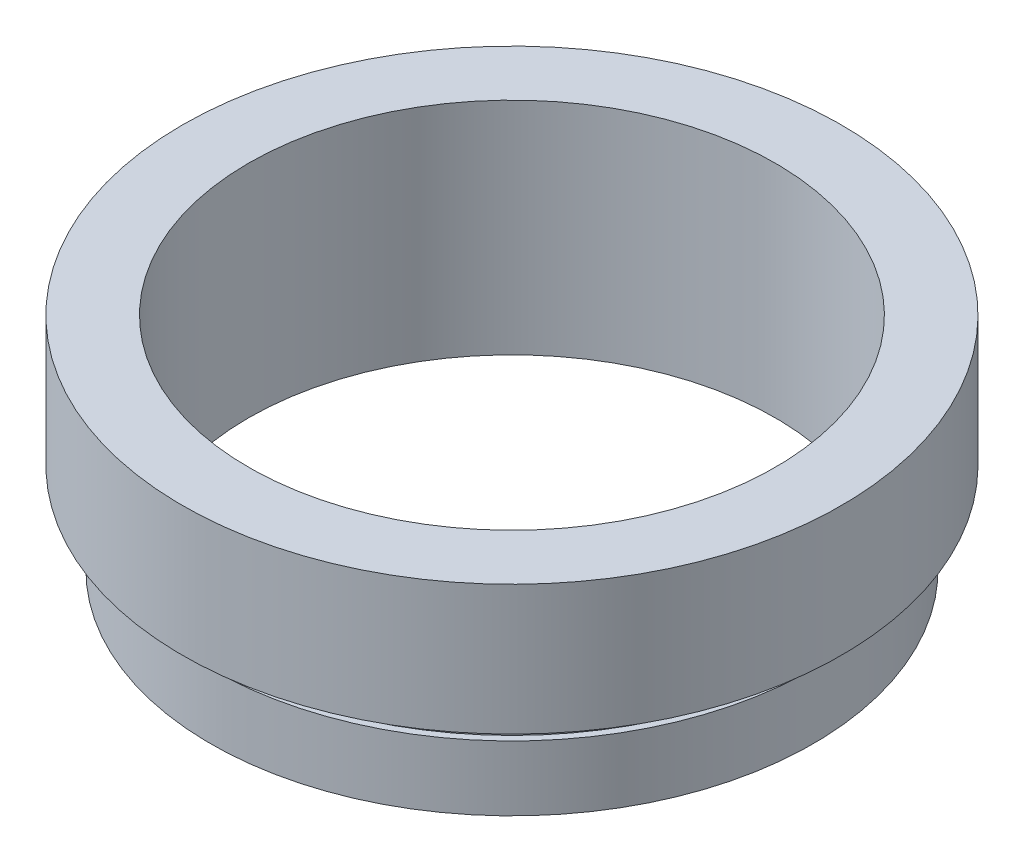
from build123d import *


with BuildPart() as part:
    # 草图1 → 旋转1 (revolve)
    with BuildSketch(Plane.XY, mode=Mode.PRIVATE) as revolve_1_sk:
        Polygon((10.15, -0.545464411), (10.15, 7.954535589), (12.7, 7.954535589), (12.7, 2.954535589), (11.35, 2.954535589), (11.35, 1.954535589), (11.61, 1.954535589), (11.61, -0.545464411), align=None)
    revolve(revolve_1_sk.sketch.rotate(Axis((0, 16.886018237, 0), (0, -1, 0)), 180), axis=Axis((0, 16.886018237, 0), (0, -1, 0)))  # turned: the seam where the file's is


solid = part.part
